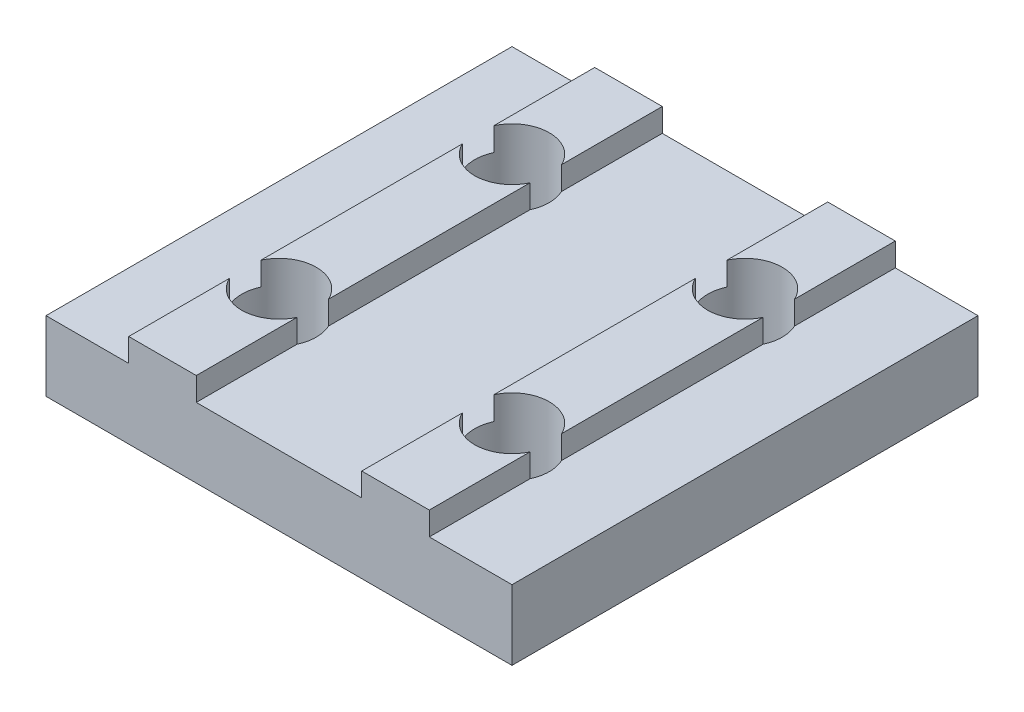
from build123d import *

# Parameters (mm, degrees)
MAIN_DEPTH                 = 20
ESQUISSE2_R                = 1.6
TOPHOLE_DEPTH              = 22
R_P_TITION_LIN_AIRE1_COUNT = 2
R_P_TITION_LIN_AIRE1_PITCH = 10


with BuildPart() as part:
    # Esquisse1 → Main (new body)
    with BuildSketch(Plane.XY):
        Polygon((-5, 0), (-5, 3), (-1.45, 3), (-1.45, 4), (1.45, 4), (1.45, 3), (5, 3), (5, 0), align=None)
    main = extrude(amount=MAIN_DEPTH)

    # Esquisse2 → TopHole (cut, through all)
    with BuildSketch(Plane(origin=(0, 4, 0), x_dir=(1, 0, 0), z_dir=(0, 1, 0))):
        with Locations((0, -5)):
            Circle(ESQUISSE2_R)
        with Locations((0, -15)):
            Circle(ESQUISSE2_R)
    tophole = extrude(amount=-TOPHOLE_DEPTH, mode=Mode.SUBTRACT)

    # Répétition linéaire1: Main, TopHole ×2
    with Locations(*[(-i * R_P_TITION_LIN_AIRE1_PITCH, 0, 0) for i in range(1, R_P_TITION_LIN_AIRE1_COUNT)]):
        add(main)
        add(tophole, mode=Mode.SUBTRACT)


solid = part.part
